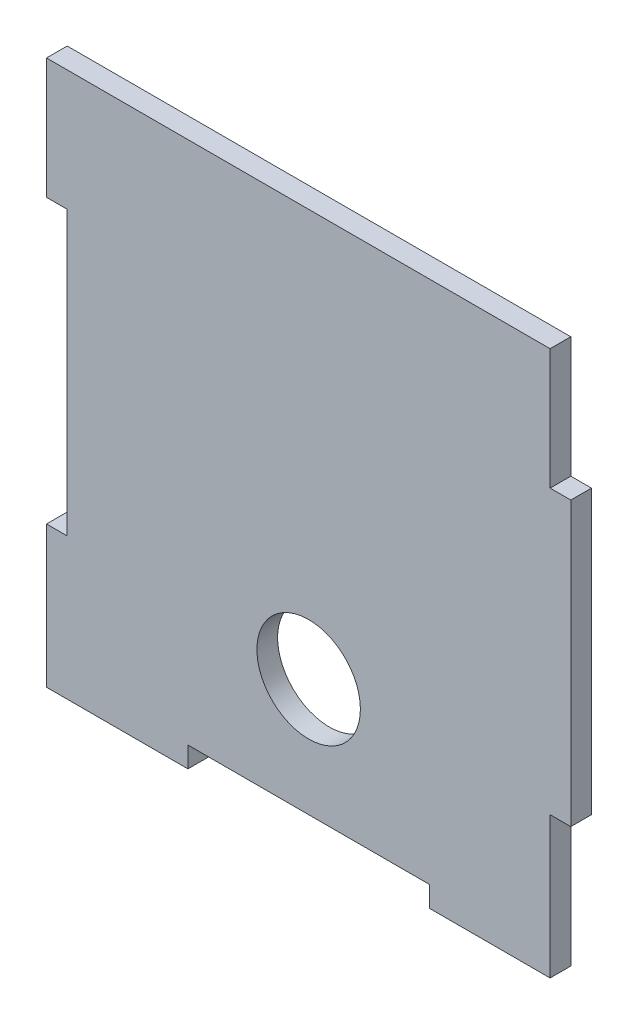
from build123d import *

# Parameters (mm, degrees)
BOSS_EXTRUDE1_DEPTH = 3
SKETCH2_R           = 7.5
CUT_EXTRUDE1_DEPTH  = 3


with BuildPart() as part:
    # Sketch1 → Boss-Extrude1 (new body)
    with BuildSketch(Plane.XY):
        Polygon((-35, 38), (-17.5, 38), (17.5, 38), (35, 38), (35, 20.5), (38, 20.5), (38, -20.5), (35, -20.5), (35, -38), (35, -41), (17.5, -41), (17.5, -38), (-17.5, -38), (-17.5, -41), (-35, -41), (-38, -41), (-38, -38), (-38, -20.5), (-35, -20.5), (-35, 20.5), (-38, 20.5), (-38, 38), align=None)
    extrude(amount=BOSS_EXTRUDE1_DEPTH)

    # Sketch2 → Cut-Extrude1 (cut)
    with BuildSketch(Plane.XY.offset(3)):
        with Locations((0, -21)):
            Circle(SKETCH2_R)
    extrude(amount=-CUT_EXTRUDE1_DEPTH, mode=Mode.SUBTRACT)


solid = part.part
